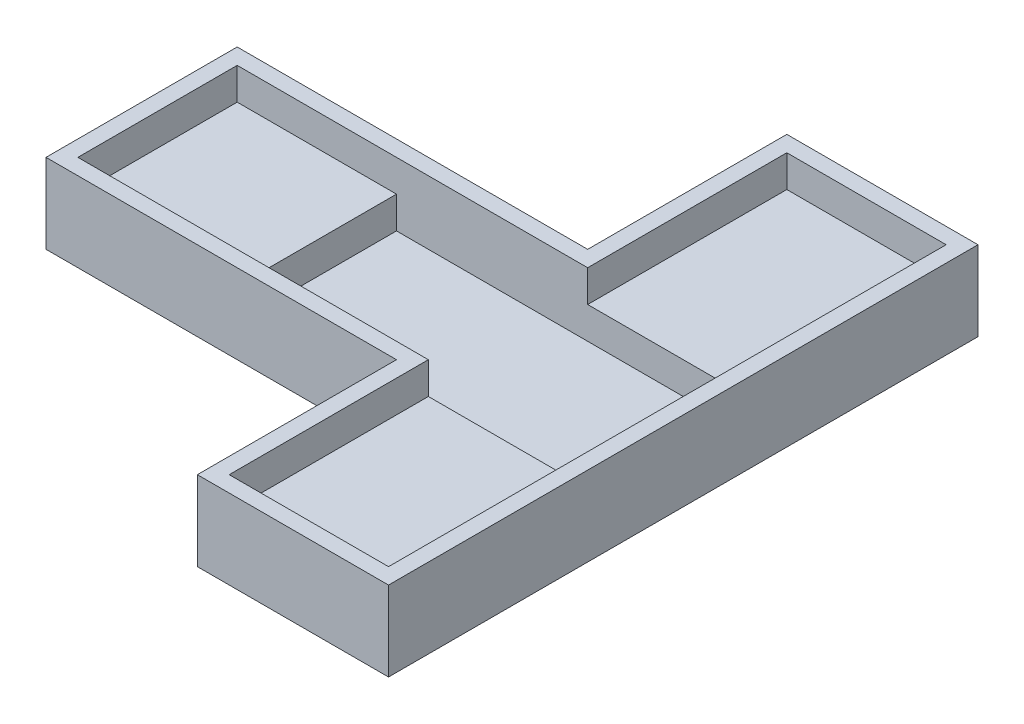
from build123d import *

# Parameters (mm, degrees)
SKETCH_2_W           = 32
SKETCH_2_H           = 10
SKETCH_2_W_2         = 10
SKETCH_2_H_2         = 12.5
EXTRUDE_1_DEPTH      = 1
EXTRUDE_2_DEPTH      = 4
EXTRUDE_2_DEPTH_BACK = 1
SKETCH_4_W           = 10
SKETCH_4_H           = 10
SKETCH_4_H_2         = 12.5
EXTRUDE_3_DEPTH      = 2


with BuildPart() as part:
    # 草图2 → 凸台-拉伸1 (new body)
    with BuildSketch(Plane(origin=(0, 0, 0), x_dir=(1, 0, 0), z_dir=(0, 1, 0))):
        with Locations((-5, 0)):
            Rectangle(SKETCH_2_W, SKETCH_2_H)
        with Locations((6, 11.25)):
            Rectangle(SKETCH_2_W_2, SKETCH_2_H_2)
        with Locations((6, -11.25)):
            Rectangle(SKETCH_2_W_2, SKETCH_2_H_2)
    extrude(amount=EXTRUDE_1_DEPTH)

    # 草图3 → 凸台-拉伸2 (add, two sides)
    with BuildSketch(Plane(origin=(0, 1, 0), x_dir=(1, 0, 0), z_dir=(0, 1, 0))) as extrude_2_sk:
        Polygon((12, -18.5), (12, 18.5), (0, 18.5), (0, 6), (-22, 6), (-22, -6), (0, -6), (0, -18.5), align=None)
        Polygon((11, -17.5), (11, 17.5), (1, 17.5), (1, 5), (-21, 5), (-21, -5), (1, -5), (1, -17.5), align=None, mode=Mode.SUBTRACT)
    extrude(amount=EXTRUDE_2_DEPTH)
    extrude(extrude_2_sk.sketch, amount=-EXTRUDE_2_DEPTH_BACK)

    # 草图4 → 凸台-拉伸3 (add)
    with BuildSketch(Plane(origin=(0, 1, 0), x_dir=(1, 0, 0), z_dir=(0, 1, 0))):
        with Locations((-16, 0)):
            Rectangle(SKETCH_4_W, SKETCH_4_H)
        with Locations((6, 11.25)):
            Rectangle(SKETCH_4_W, SKETCH_4_H_2)
        with Locations((6, -11.25)):
            Rectangle(SKETCH_4_W, SKETCH_4_H_2)
    extrude(amount=EXTRUDE_3_DEPTH)


solid = part.part
